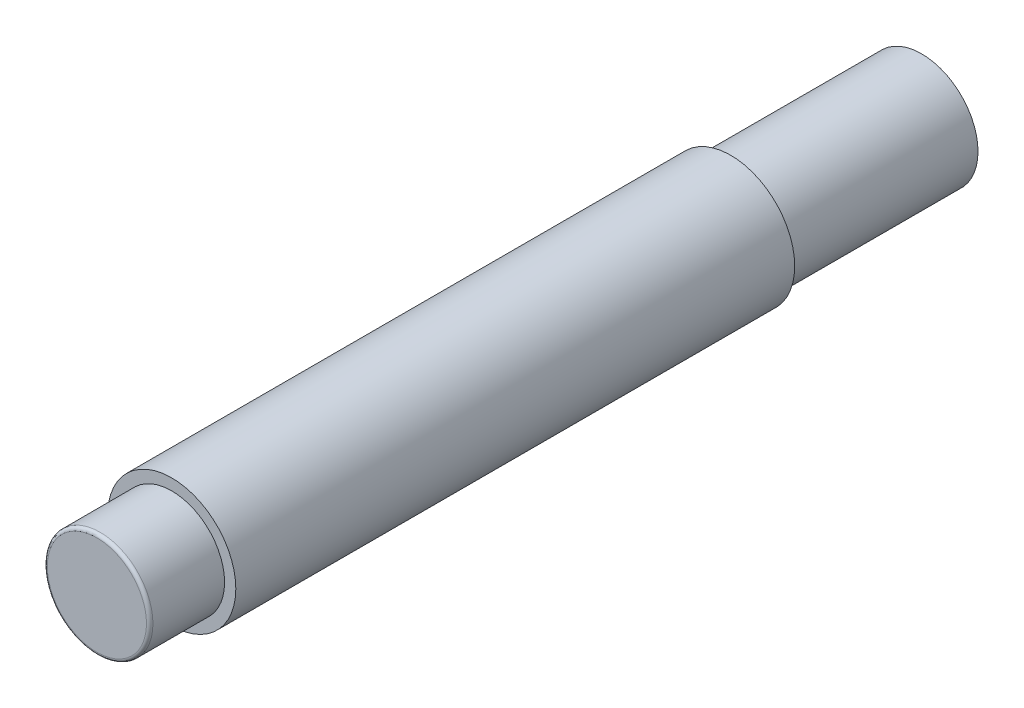
from build123d import *

# Parameters (mm, degrees)
FILLET1_R = 0.2


with BuildPart() as part:
    # Sketch1 → Revolve1 (revolve)
    with BuildSketch(Plane(origin=(0, 0, 0), x_dir=(0, 0, -1), z_dir=(1, 0, 0))):
        Polygon((0, 0), (0, 3.265), (4.63, 3.265), (4.63, 3.96), (39.19, 3.96), (39.19, 3.485), (51, 3.485), (51, 0), align=None)
    revolve(axis=Axis((0, 0, 22.591484059), (0, 0, -1)))

    # Fillet1
    fillet1_edges = [part.edges().sort_by_distance(p)[0] for p in [
        (0, -3.265, 0),
    ]]
    fillet(fillet1_edges, radius=FILLET1_R)


solid = part.part
